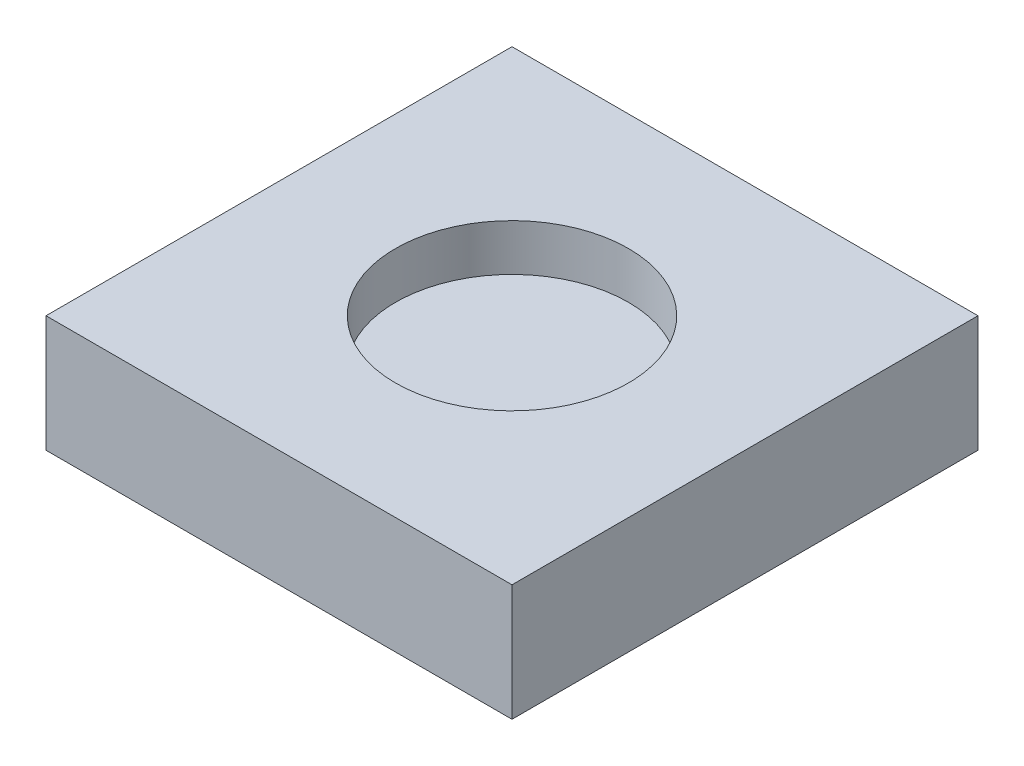
from build123d import *

# Parameters (mm, degrees)
SKETCH1_W           = 20
SKETCH1_H           = 20
BOSS_EXTRUDE1_DEPTH = 5
SKETCH2_R           = 5
CUT_EXTRUDE1_DEPTH  = 2
SKETCH3_R           = 1
CUT_EXTRUDE2_DEPTH  = 2
FILLET1_R           = 1


with BuildPart() as part:
    # Sketch1 → Boss-Extrude1 (new body)
    with BuildSketch(Plane(origin=(0, 0, 0), x_dir=(1, 0, 0), z_dir=(0, 1, 0))):
        Rectangle(SKETCH1_W, SKETCH1_H)
    extrude(amount=BOSS_EXTRUDE1_DEPTH)

    # Sketch2 → Cut-Extrude1 (cut)
    with BuildSketch(Plane(origin=(0, 5, 0), x_dir=(1, 0, 0), z_dir=(0, 1, 0))):
        Circle(SKETCH2_R)
    extrude(amount=-CUT_EXTRUDE1_DEPTH, mode=Mode.SUBTRACT)

    # Sketch3 → Cut-Extrude2 (cut)
    with BuildSketch(Plane.XZ):
        Circle(SKETCH3_R)
    extrude(amount=-CUT_EXTRUDE2_DEPTH, mode=Mode.SUBTRACT)

    # Fillet1
    fillet1_edges = [part.edges().sort_by_distance(p)[0] for p in [
        (-1, 2, 0),
    ]]
    fillet(fillet1_edges, radius=FILLET1_R)


solid = part.part
